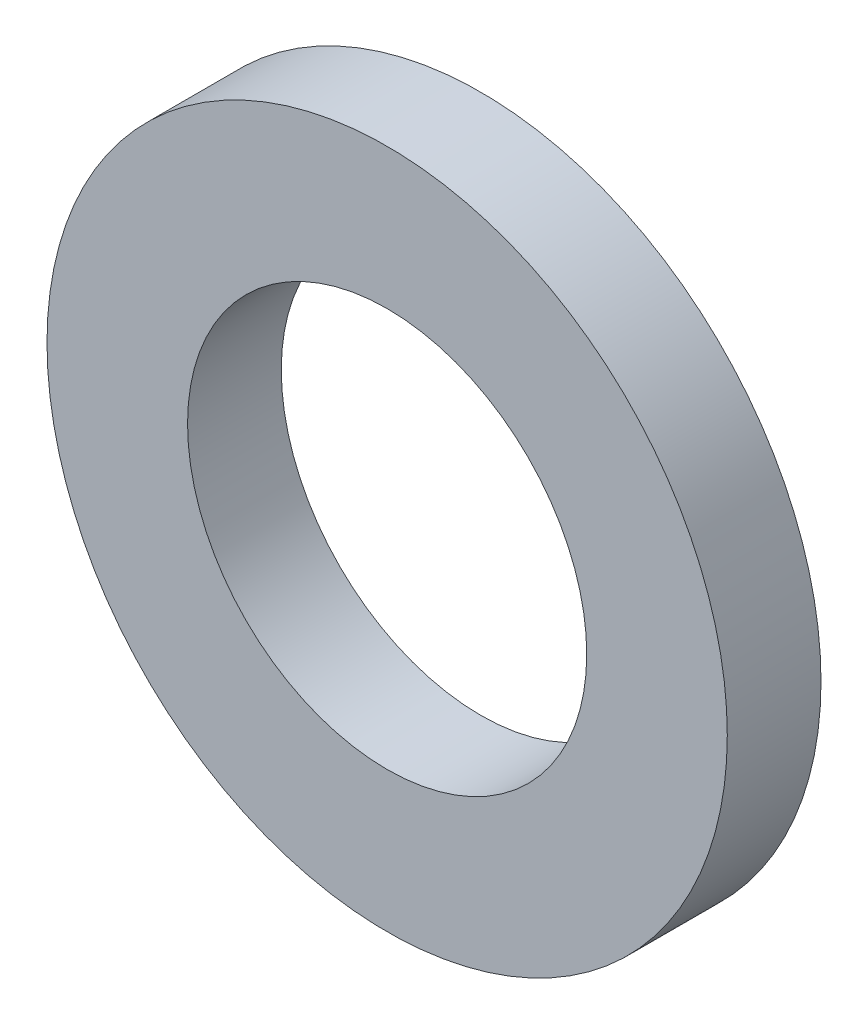
from build123d import *

# Parameters (mm, degrees)
SKETCH1_R           = 36.3
SKETCH1_R_2         = 21.3
BOSS_EXTRUDE1_DEPTH = 10


with BuildPart() as part:
    # Sketch1 → Boss-Extrude1 (new body)
    with BuildSketch(Plane.XY):
        Circle(SKETCH1_R)
        Circle(SKETCH1_R_2, mode=Mode.SUBTRACT)
    extrude(amount=BOSS_EXTRUDE1_DEPTH)


solid = part.part
